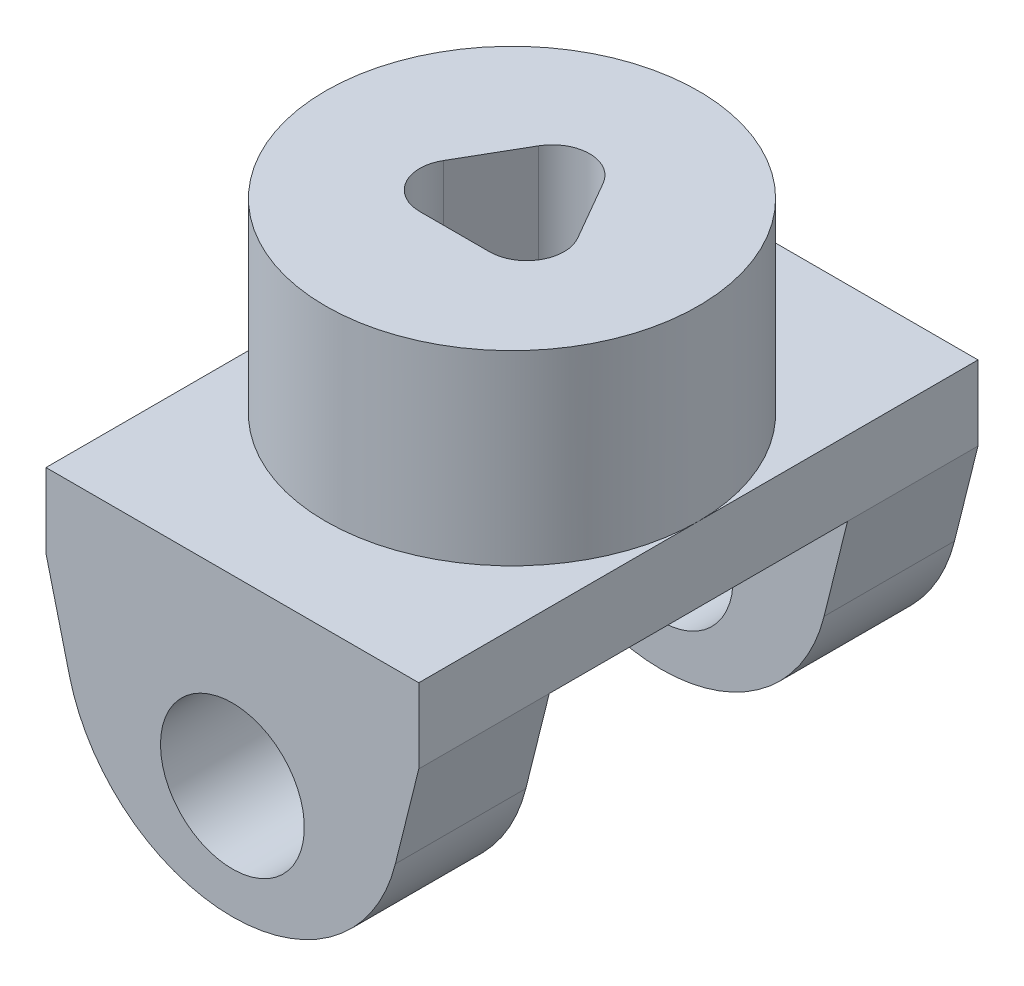
from build123d import *

# Parameters (mm, degrees)
SKETCH1_R               = 6.35
BOSS_EXTRUDE1_DEPTH     = 6.35
SKETCH1_5_W             = 12.7
SKETCH1_5_H             = 19.05
BOSS_EXTRUDE3_DEPTH     = 10.16
CUT_EXTRUDE1_DEPTH      = 7.62
CUT_EXTRUDE3_DEPTH      = 23.504457336
CUT_EXTRUDE3_DEPTH_BACK = 23.504457336
SKETCH5_4_R             = 2.4500078
CUT_EXTRUDE4_DEPTH      = 23.468888119
CUT_EXTRUDE5_DEPTH      = 16.253657211
CUT_EXTRUDE5_DEPTH_BACK = 16.253657211
SKETCH6_W               = 10.16
SKETCH6_H               = 12.113180789


with BuildPart() as part:
    # Sketch1 → Boss-Extrude1 (new body)
    with BuildSketch(Plane(origin=(0, 0, 0), x_dir=(1, 0, 0), z_dir=(0, 1, 0))):
        Circle(SKETCH1_R)
    extrude(amount=BOSS_EXTRUDE1_DEPTH)

    # Sketch1_5 → Boss-Extrude3 (add)
    with BuildSketch(Plane(origin=(0, 0, 0), x_dir=(1, 0, 0), z_dir=(0, 1, 0))):
        Rectangle(SKETCH1_5_W, SKETCH1_5_H)
    extrude(amount=-BOSS_EXTRUDE3_DEPTH)

    # Sketch3 → Cut-Extrude1 (cut)
    with BuildSketch(Plane(origin=(0, 6.35, 0), x_dir=(1, 0, 0), z_dir=(0, 1, 0))):
        with BuildLine():
            Line((-1.099852263, 2.007933515), (-2.288847564, -0.051466757))
            ThreePointArc((-2.288847564, -0.051466757), (-2.288847564, -1.321466757), (-1.188995301, -1.956466757))
            Line((-1.188995301, -1.956466757), (1.188995301, -1.956466757))
            ThreePointArc((1.188995301, -1.956466757), (2.288847564, -1.321466757), (2.288847564, -0.051466757))
            Line((2.288847564, -0.051466757), (1.099852263, 2.007933515))
            ThreePointArc((1.099852263, 2.007933515), (0, 2.642933515), (-1.099852263, 2.007933515))
        make_face()
    extrude(amount=-CUT_EXTRUDE1_DEPTH, mode=Mode.SUBTRACT)

    # Sketch5 → Cut-Extrude3 (cut, two sides: drawn at the far end of the back side and taken through both)
    with BuildSketch(Plane(origin=(0, 0, -9.525), x_dir=(-1, 0, 0), z_dir=(0, 0, -1)).offset(-CUT_EXTRUDE3_DEPTH_BACK)):
        with BuildLine():
            Line((-16.269922962, 37.246637879), (-6.35, -2.54))
            Line((-6.35, -2.54), (-5.551173901, -5.743916488))
            ThreePointArc((-5.551173901, -5.743916488), (0, -10.080968867), (5.551173901, -5.743916488))
            Line((5.551173901, -5.743916488), (6.35, -2.54))
            Line((6.35, -2.54), (16.269922962, 37.246637879))
            Line((16.269922962, 37.246637879), (16.269922962, -44.762664649))
            Line((16.269922962, -44.762664649), (-16.269922962, -44.762664649))
            Line((-16.269922962, -44.762664649), (-16.269922962, 37.246637879))
        make_face()
    extrude(amount=CUT_EXTRUDE3_DEPTH + CUT_EXTRUDE3_DEPTH_BACK, mode=Mode.SUBTRACT)

    # Sketch5_4 → Cut-Extrude4 (cut, through all)
    with BuildSketch(Plane(origin=(0, 0, -9.525), x_dir=(-1, 0, 0), z_dir=(0, 0, -1))):
        with Locations((0, -6.219754937)):
            Circle(SKETCH5_4_R)
    extrude(amount=-CUT_EXTRUDE4_DEPTH, mode=Mode.SUBTRACT)

    # Sketch6 → Cut-Extrude5 (cut, two sides: drawn at the far end of the back side and taken through both)
    with BuildSketch(Plane(origin=(0, 0, 0), x_dir=(0, 0, -1), z_dir=(1, 0, 0)).offset(-CUT_EXTRUDE5_DEPTH_BACK)):
        with Locations((0, -8.596590394)):
            Rectangle(SKETCH6_W, SKETCH6_H)
    extrude(amount=CUT_EXTRUDE5_DEPTH + CUT_EXTRUDE5_DEPTH_BACK, mode=Mode.SUBTRACT)


solid = part.part
